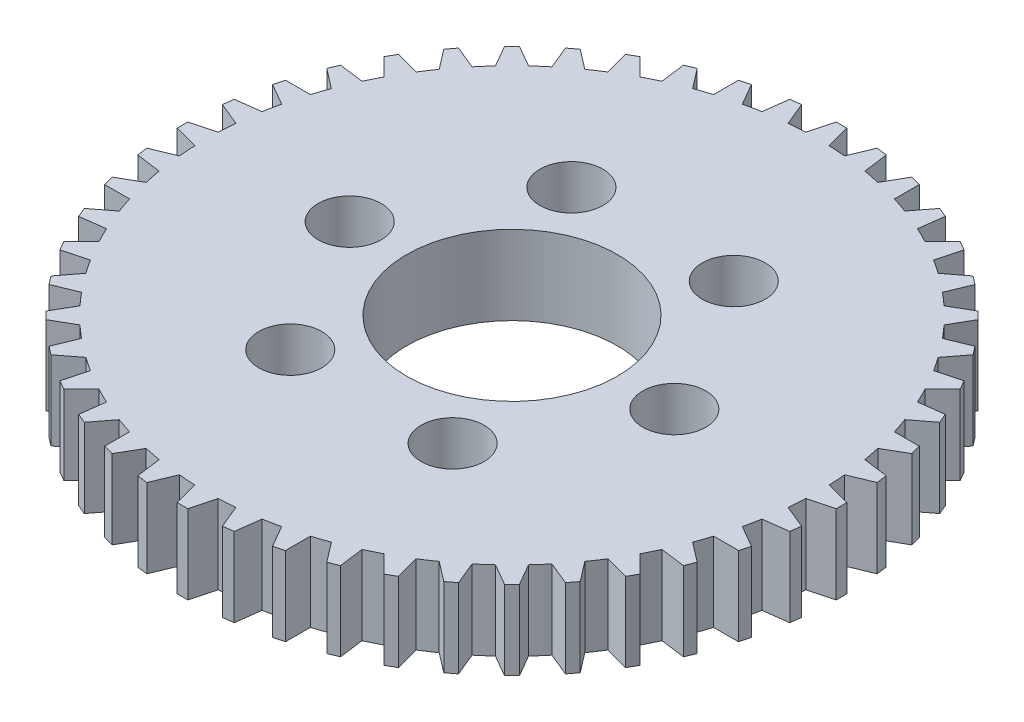
from build123d import *

# Parameters (mm, degrees)
SKETCH1_R             = 18.415
SKETCH1_R_2           = 6.35
BOSS_EXTRUDE1_DEPTH   = 4.7625
BOSS_EXTRUDE2_DEPTH   = 4.7625
CIRPATTERN1_COUNT     = 48
F_6_CLEARANCE_HOLE1_D = 3.7973
CIRPATTERN2_COUNT     = 6


with BuildPart() as part:
    # Sketch1 → Boss-Extrude1 (new body)
    with BuildSketch(Plane(origin=(0, 0, 0), x_dir=(1, 0, 0), z_dir=(0, 1, 0))):
        Circle(SKETCH1_R)
        Circle(SKETCH1_R_2, mode=Mode.SUBTRACT)
    extrude(amount=BOSS_EXTRUDE1_DEPTH)

    # Sketch2 → Boss-Extrude2 (add)
    with BuildSketch(Plane(origin=(0, 4.7625, 0), x_dir=(1, 0, 0), z_dir=(0, 1, 0))):
        Polygon((-1.134209139, 16.8021), (1.134209139, 16.8021), (0.3175, 19.8501), (-0.3175, 19.8501), align=None)
    boss_extrude2 = extrude(amount=-BOSS_EXTRUDE2_DEPTH)

    # CirPattern1: Boss-Extrude2 ×48 about axis
    cirpattern1_axis = Axis((0, 0, 0), (0, 1, 0))
    for i in range(1, CIRPATTERN1_COUNT):
        add(boss_extrude2.rotate(cirpattern1_axis, i * 360 / CIRPATTERN1_COUNT))

    # #6 Clearance Hole1 (through all)
    with Locations(Plane(origin=(0, 4.7625, 0), x_dir=(1, 0, 0), z_dir=(0, 1, 0))):
        with Locations((9.779, 0)):
            f_6_clearance_hole1 = Hole(F_6_CLEARANCE_HOLE1_D / 2)

    # CirPattern2: #6 Clearance Hole1 ×6 about axis
    cirpattern2_axis = Axis((0, 0, 0), (0, 1, 0))
    for i in range(1, CIRPATTERN2_COUNT):
        add(f_6_clearance_hole1.rotate(cirpattern2_axis, i * 360 / CIRPATTERN2_COUNT), mode=Mode.SUBTRACT)


solid = part.part
